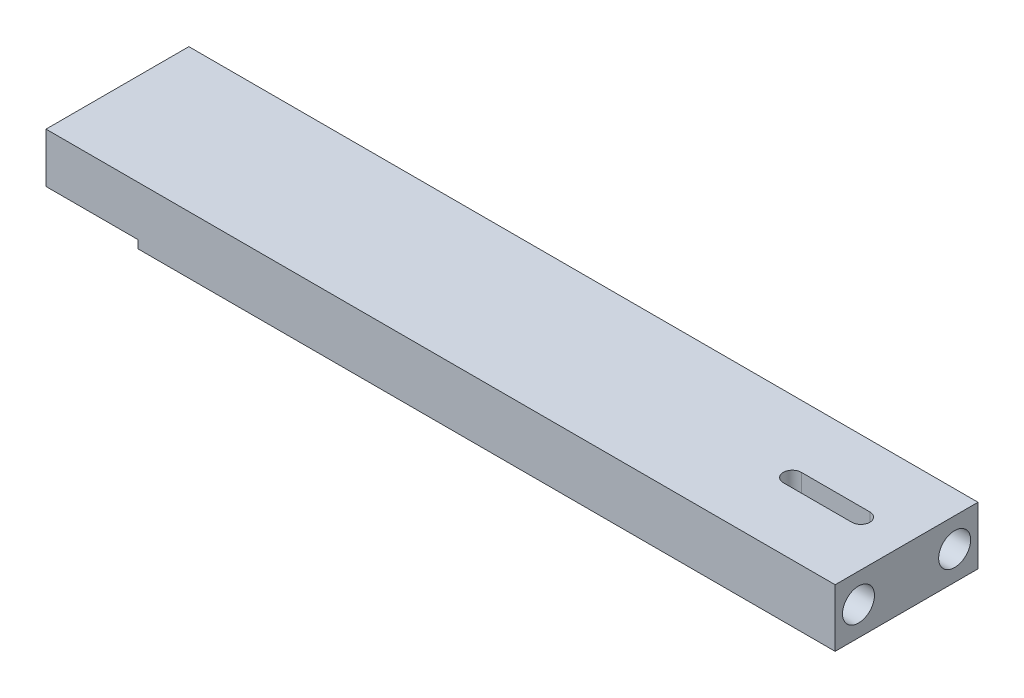
from build123d import *

# Parameters (mm, degrees)
CROQUIS1_W              = 139.5
CROQUIS1_H              = 25
SALIENTE_EXTRUIR1_DEPTH = 10.1
CORTAR_EXTRUIR1_DEPTH   = 26
CROQUIS3_R              = 2.675
CORTAR_EXTRUIR2_DEPTH   = 15
CORTAR_EXTRUIR3_DEPTH   = 11.1
CORTAR_EXTRUIR4_DEPTH   = 5.5
CROQUIS7_R              = 2.8
CORTAR_EXTRUIR5_DEPTH   = 15


with BuildPart() as part:
    # Croquis1 → Saliente-Extruir1 (new body)
    with BuildSketch(Plane(origin=(0, 0, 0), x_dir=(1, 0, 0), z_dir=(0, 1, 0))):
        Rectangle(CROQUIS1_W, CROQUIS1_H)
    extrude(amount=SALIENTE_EXTRUIR1_DEPTH)

    # Croquis2 → Cortar-Extruir1 (cut, through all)
    with BuildSketch(Plane.XY.offset(12.5)):
        Polygon((-69.75, 10.1), (-69.75, 0), (-52.25, 0), (-52.25, 1.4), (-68.35, 1.4), (-68.35, 10.1), align=None)
    extrude(amount=-CORTAR_EXTRUIR1_DEPTH, mode=Mode.SUBTRACT)

    # Croquis3 → Cortar-Extruir2 (cut)
    with BuildSketch(Plane.ZY.offset(68.35)):
        with Locations((-7.5, 5.75)):
            Circle(CROQUIS3_R)
        with Locations((7.5, 5.75)):
            Circle(CROQUIS3_R)
    extrude(amount=-CORTAR_EXTRUIR2_DEPTH, mode=Mode.SUBTRACT)

    # Croquis4 → Cortar-Extruir3 (cut, through all)
    with BuildSketch(Plane(origin=(0, 10.1, 0), x_dir=(1, 0, 0), z_dir=(0, 1, 0))):
        with BuildLine():
            Line((49.75, 1.575), (61.75, 1.575))
            ThreePointArc((61.75, 1.575), (63.325, 0), (61.75, -1.575))
            Line((61.75, -1.575), (49.75, -1.575))
            ThreePointArc((49.75, -1.575), (48.175, 0), (49.75, 1.575))
        make_face()
    extrude(amount=-CORTAR_EXTRUIR3_DEPTH, mode=Mode.SUBTRACT)

    # Croquis5 → Cortar-Extruir4 (cut)
    with BuildSketch(Plane.XZ):
        with BuildLine():
            Line((49.75, 4.325), (61.75, 4.325))
            ThreePointArc((61.75, 4.325), (66.075, 0), (61.75, -4.325))
            Line((61.75, -4.325), (49.75, -4.325))
            ThreePointArc((49.75, -4.325), (45.425, 0), (49.75, 4.325))
        make_face()
    extrude(amount=-CORTAR_EXTRUIR4_DEPTH, mode=Mode.SUBTRACT)

    # Croquis7 → Cortar-Extruir5 (cut)
    with BuildSketch(Plane(origin=(69.75, 0, 0), x_dir=(0, 0, -1), z_dir=(1, 0, 0))):
        with Locations((-8.4125, 5.05)):
            Circle(CROQUIS7_R)
        with Locations((8.4125, 5.05)):
            Circle(CROQUIS7_R)
    extrude(amount=-CORTAR_EXTRUIR5_DEPTH, mode=Mode.SUBTRACT)


solid = part.part
